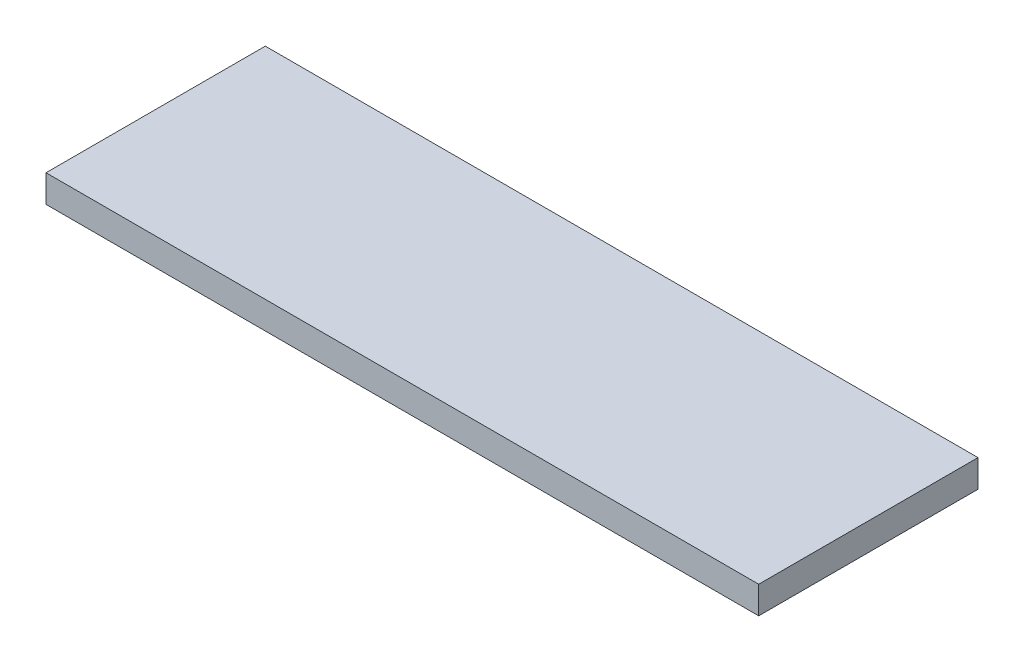
from build123d import *

# Parameters (mm, degrees)
SKETCH1_W           = 330.2
SKETCH1_H           = 101.6
BOSS_EXTRUDE1_DEPTH = 12.7


with BuildPart() as part:
    # Sketch1 → Boss-Extrude1 (new body)
    with BuildSketch(Plane(origin=(0, 0, 0), x_dir=(1, 0, 0), z_dir=(0, 1, 0))):
        with Locations((104.756600121, 32.49438188)):
            Rectangle(SKETCH1_W, SKETCH1_H)
    extrude(amount=BOSS_EXTRUDE1_DEPTH)


solid = part.part
